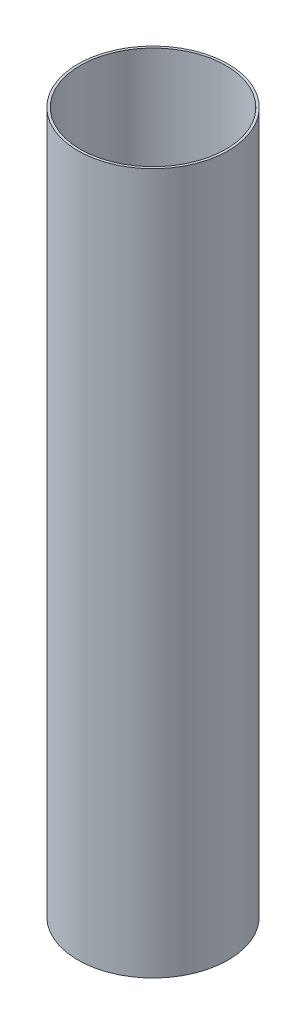
from build123d import *

# Parameters (mm, degrees)
SKETCH1_R           = 101.727
SKETCH1_R_2         = 98.425
EXTRUDE_THIN1_DEPTH = 948.69


with BuildPart() as part:
    # Sketch1 → Extrude-Thin1 (new body)
    with BuildSketch(Plane(origin=(0, 0, 0), x_dir=(1, 0, 0), z_dir=(0, 1, 0))):
        Circle(SKETCH1_R)
        Circle(SKETCH1_R_2, mode=Mode.SUBTRACT)
    extrude(amount=EXTRUDE_THIN1_DEPTH)


solid = part.part
